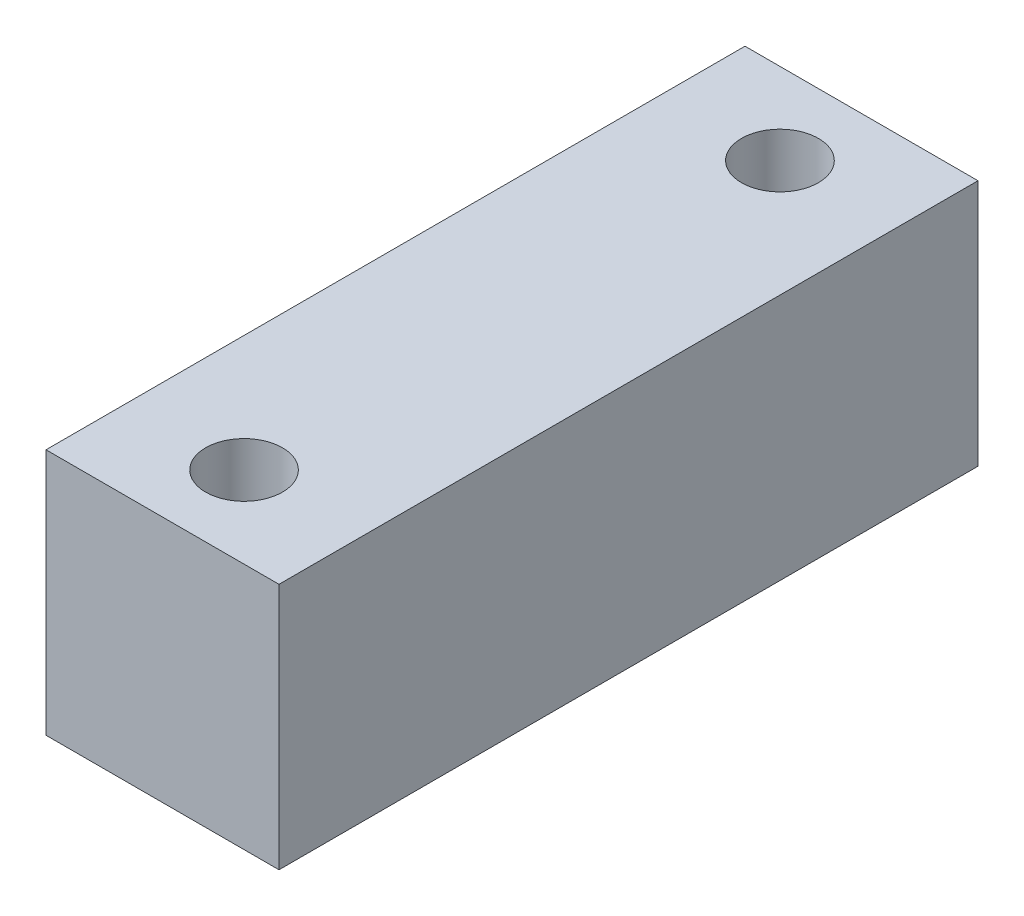
from build123d import *

# Parameters (mm, degrees)
SKETCH1_W           = 20
SKETCH1_H           = 60
SKETCH1_R           = 3.3
BOSS_EXTRUDE1_DEPTH = 21.22424


with BuildPart() as part:
    # Sketch1 → Boss-Extrude1 (new body)
    with BuildSketch(Plane(origin=(0, 0, 0), x_dir=(1, 0, 0), z_dir=(0, 1, 0))):
        with Locations((-10, 0)):
            Rectangle(SKETCH1_W, SKETCH1_H)
        with Locations((-10, 23)):
            Circle(SKETCH1_R, mode=Mode.SUBTRACT)
        with Locations((-10, -23)):
            Circle(SKETCH1_R, mode=Mode.SUBTRACT)
    extrude(amount=BOSS_EXTRUDE1_DEPTH)


solid = part.part
